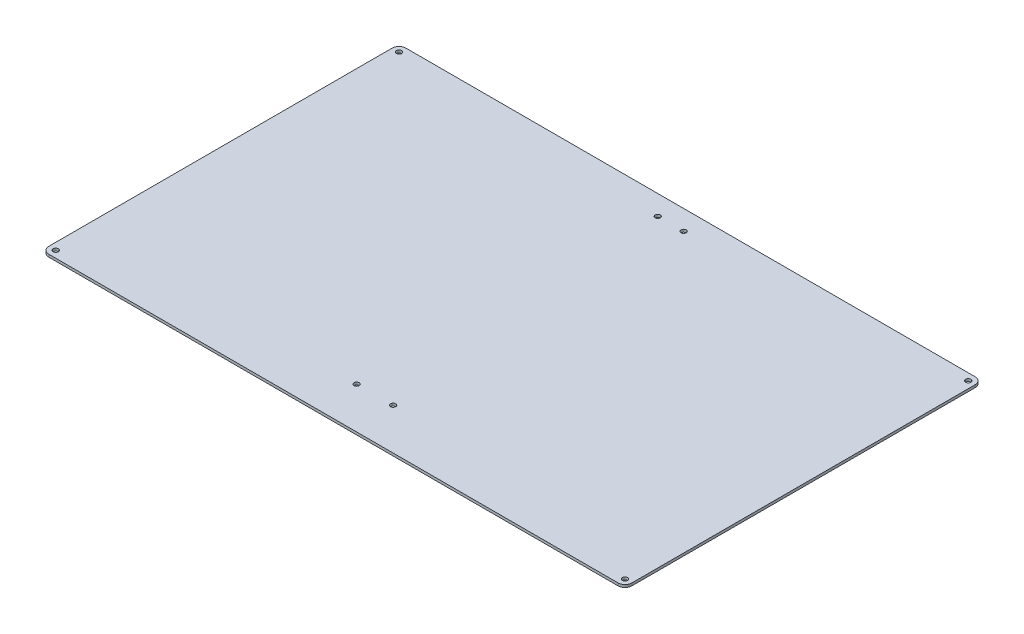
from build123d import *

# Parameters (mm, degrees)
SKETCH1_W                 = 338
SKETCH1_H                 = 207
BOSS_EXTRUDE1_DEPTH       = 1.5
FILLET1_R                 = 4
F_3_0MM_DOWEL_HOLE1_D     = 3
F_3_0MM_DOWEL_HOLE1_DEPTH = 17.29
F_3_0MM_DOWEL_HOLE1_TIP   = 0.901290929


with BuildPart() as part:
    # Sketch1 → Boss-Extrude1 (new body)
    with BuildSketch(Plane(origin=(0, 0, 0), x_dir=(1, 0, 0), z_dir=(0, 1, 0))):
        Rectangle(SKETCH1_W, SKETCH1_H)
    extrude(amount=BOSS_EXTRUDE1_DEPTH)

    # Fillet1
    fillet1_edges = [part.edges().sort_by_distance(p)[0] for p in [
        (-169, 0.75, -103.5),
        (169, 0.75, -103.5),
        (169, 0.75, 103.5),
        (-169, 0.75, 103.5),
    ]]
    fillet(fillet1_edges, radius=FILLET1_R)

    # Ø3.0mm Dowel Hole1
    with Locations(Plane(origin=(0, 1.5, 0), x_dir=(1, 0, 0), z_dir=(0, 1, 0))):
        with Locations((-165, -99.5), (-165, 99.5), (165, 99.5), (165, -99.5), (-10.577889447, -79.5), (10.577889447, -79.5), (-7.5, 92), (7.5, 92)):
            Hole(F_3_0MM_DOWEL_HOLE1_D / 2, depth=F_3_0MM_DOWEL_HOLE1_DEPTH)
            with Locations((0, 0, -(F_3_0MM_DOWEL_HOLE1_DEPTH + F_3_0MM_DOWEL_HOLE1_TIP / 2))):  # 118° drill point
                Cone(0, F_3_0MM_DOWEL_HOLE1_D / 2, F_3_0MM_DOWEL_HOLE1_TIP, mode=Mode.SUBTRACT)


solid = part.part
